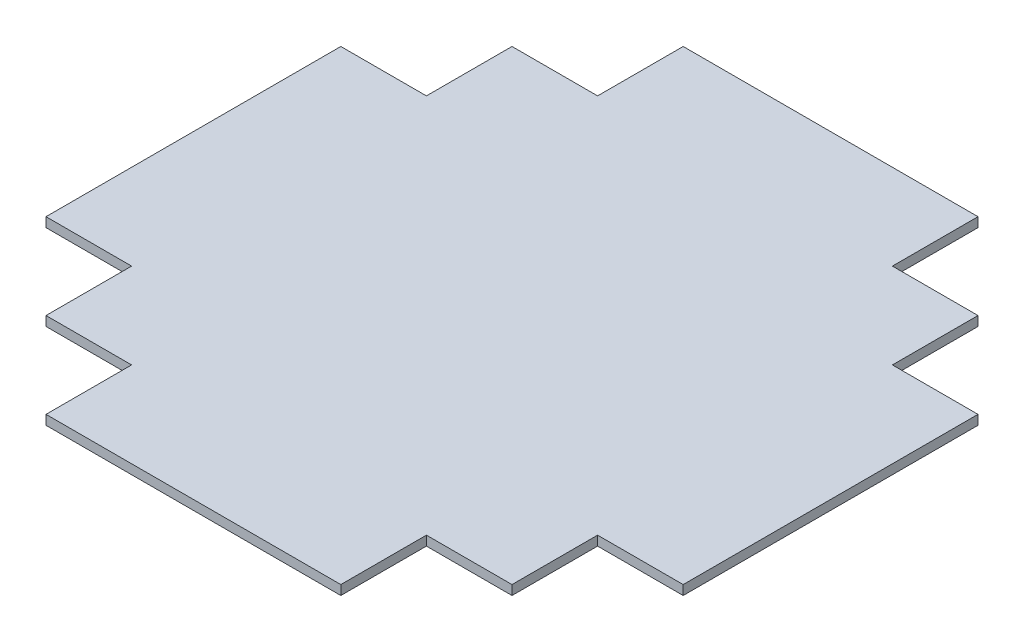
from build123d import *

# Parameters (mm, degrees)
BOSS_EXTRUDE1_DEPTH = 2


with BuildPart() as part:
    # Sketch1 → Boss-Extrude1 (new body)
    with BuildSketch(Plane(origin=(0, 0, 0), x_dir=(1, 0, 0), z_dir=(0, 1, 0))):
        Polygon((-62, 0), (-62, -18), (-80, -18), (-80, -36), (-98, -36), (-98, -98), (-80, -98), (-80, -116), (-62, -116), (-62, -134), (0, -134), (0, -116), (18, -116), (18, -98), (36, -98), (36, -36), (18, -36), (18, -18), (0, -18), (0, 0), align=None)
    extrude(amount=BOSS_EXTRUDE1_DEPTH)


solid = part.part
